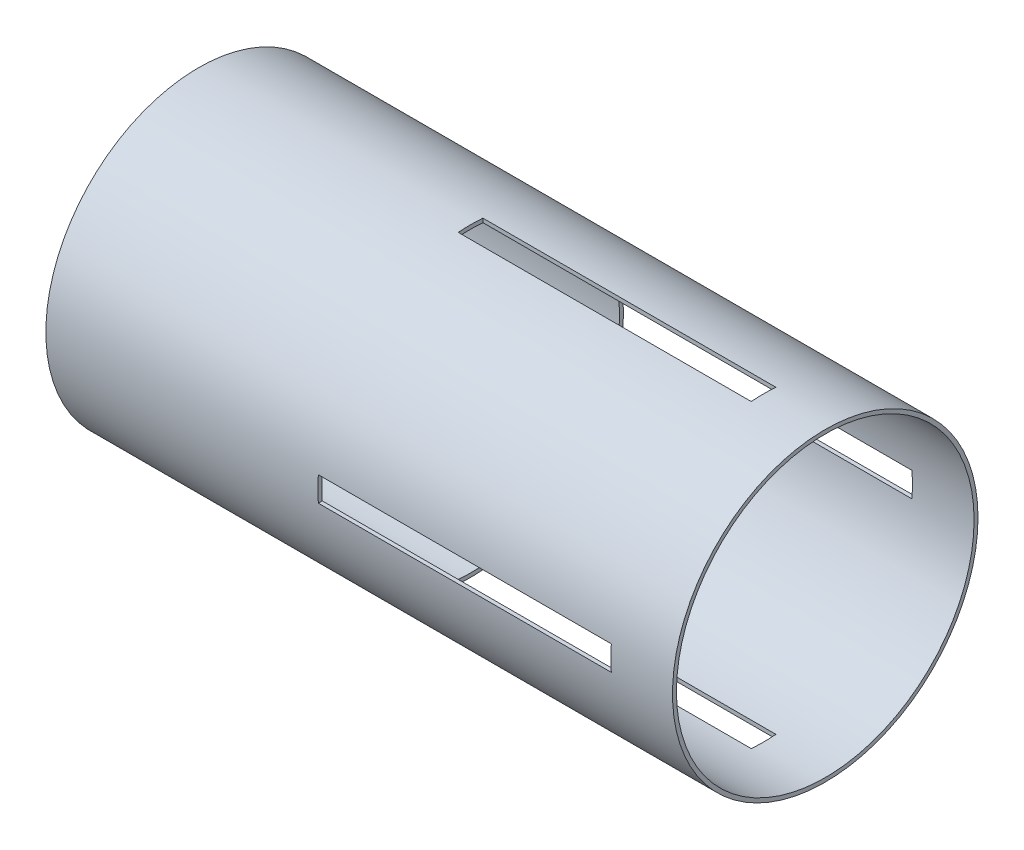
from build123d import *

# Parameters (mm, degrees)
SKETCH2_R           = 49.53
SKETCH2_R_2         = 48.26
BOSS_EXTRUDE1_DEPTH = 203.2
SKETCH4_W           = 95
SKETCH4_H           = 4
CUT_EXTRUDE1_DEPTH  = 4
CIRPATTERN1_COUNT   = 4


with BuildPart() as part:
    # Sketch2 → Boss-Extrude1 (new body)
    with BuildSketch(Plane(origin=(0, 0, 0), x_dir=(0, 0, -1), z_dir=(1, 0, 0))):
        Circle(SKETCH2_R)
        Circle(SKETCH2_R_2, mode=Mode.SUBTRACT)
    extrude(amount=BOSS_EXTRUDE1_DEPTH)

    # Sketch4 → Cut-Extrude1 (cut, symmetric)
    with BuildSketch(Plane.XY):
        with Locations((135.7, 47.53)):
            Rectangle(SKETCH4_W, SKETCH4_H)
    cut_extrude1 = extrude(amount=CUT_EXTRUDE1_DEPTH, both=True, mode=Mode.SUBTRACT)

    # CirPattern1: Cut-Extrude1 ×4 about axis
    cirpattern1_axis = Axis((0, 0, 0), (1, 0, 0))
    for i in range(1, CIRPATTERN1_COUNT):
        add(cut_extrude1.rotate(cirpattern1_axis, i * 360 / CIRPATTERN1_COUNT), mode=Mode.SUBTRACT)


solid = part.part
